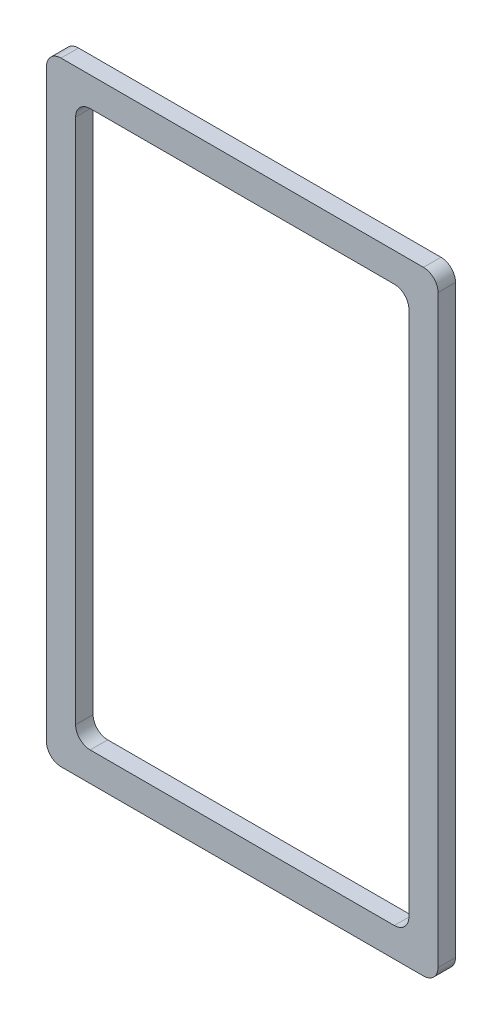
from build123d import *

# Parameters (mm, degrees)
EXTRUDE_1_DEPTH = 3


with BuildPart() as part:
    # 草图1 → 凸台-拉伸1 (new body)
    with BuildSketch(Plane.XY):
        with BuildLine():
            Line((2.5, 0), (64.6502, 0))
            ThreePointArc((64.6502, 0), (66.417966953, 0.732233047), (67.1502, 2.5))
            Line((67.1502, 2.5), (67.1502, 102.7498))
            ThreePointArc((67.1502, 102.7498), (66.417966953, 104.517566953), (64.6502, 105.2498))
            Line((64.6502, 105.2498), (2.5, 105.2498))
            ThreePointArc((2.5, 105.2498), (0.732233047, 104.517566953), (0, 102.7498))
            Line((0, 102.7498), (0, 2.5))
            ThreePointArc((0, 2.5), (0.732233047, 0.732233047), (2.5, 0))
        make_face()
        with BuildLine():
            Line((7.5, 100.2498), (59.6502, 100.2498))
            ThreePointArc((59.6502, 100.2498), (61.417966953, 99.517566953), (62.1502, 97.7498))
            Line((62.1502, 97.7498), (62.1502, 7.5))
            ThreePointArc((62.1502, 7.5), (61.417966953, 5.732233047), (59.6502, 5))
            Line((59.6502, 5), (7.5, 5))
            ThreePointArc((7.5, 5), (5.732233047, 5.732233047), (5, 7.5))
            Line((5, 7.5), (5, 97.7498))
            ThreePointArc((5, 97.7498), (5.732233047, 99.517566953), (7.5, 100.2498))
        make_face(mode=Mode.SUBTRACT)
    extrude(amount=EXTRUDE_1_DEPTH)


solid = part.part
